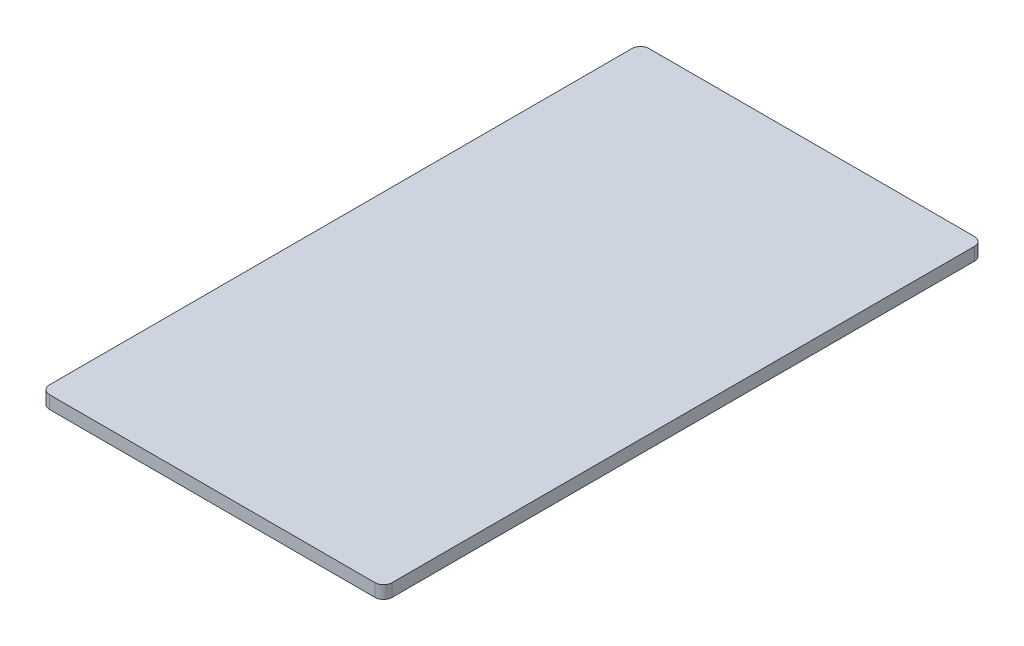
from build123d import *

# Parameters (mm, degrees)
SKETCH_1_W      = 40
SKETCH_1_H      = 70
EXTRUDE_1_DEPTH = 1.5
FILLET_2_R      = 1


with BuildPart() as part:
    # Эскиз1 → Бобышка-Вытянуть1 (new body)
    with BuildSketch(Plane(origin=(0, 0, 0), x_dir=(1, 0, 0), z_dir=(0, 1, 0))):
        Rectangle(SKETCH_1_W, SKETCH_1_H)
    extrude(amount=EXTRUDE_1_DEPTH)

    # Скругление2
    fillet_2_edges = [part.edges().sort_by_distance(p)[0] for p in [
        (20, 0.75, 35),
        (-20, 0.75, 35),
        (-20, 0.75, -35),
        (20, 0.75, -35),
    ]]
    fillet(fillet_2_edges, radius=FILLET_2_R)


solid = part.part
